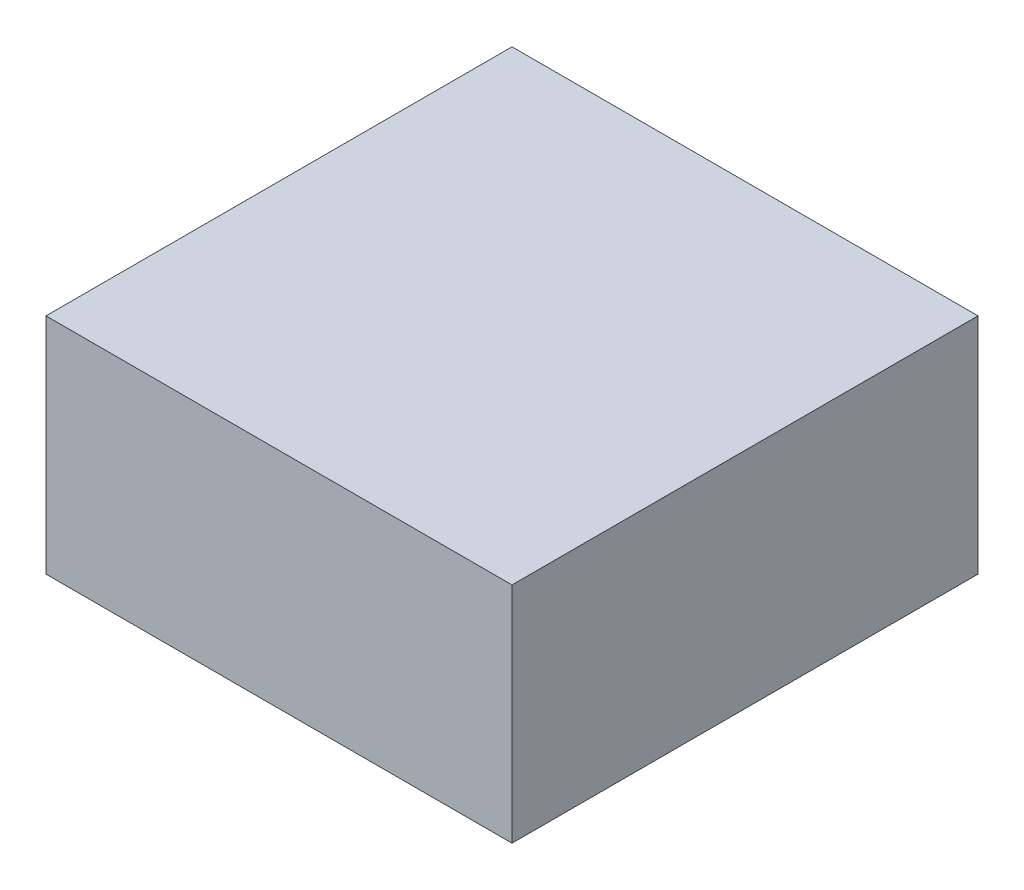
from build123d import *

# Parameters (mm, degrees)
SKETCH1_W           = 250
SKETCH1_H           = 250
BOSS_EXTRUDE1_DEPTH = 120


with BuildPart() as part:
    # Sketch1 → Boss-Extrude1 (new body)
    with BuildSketch(Plane(origin=(0, 0, 0), x_dir=(1, 0, 0), z_dir=(0, 1, 0))):
        Rectangle(SKETCH1_W, SKETCH1_H)
    extrude(amount=BOSS_EXTRUDE1_DEPTH)


solid = part.part
